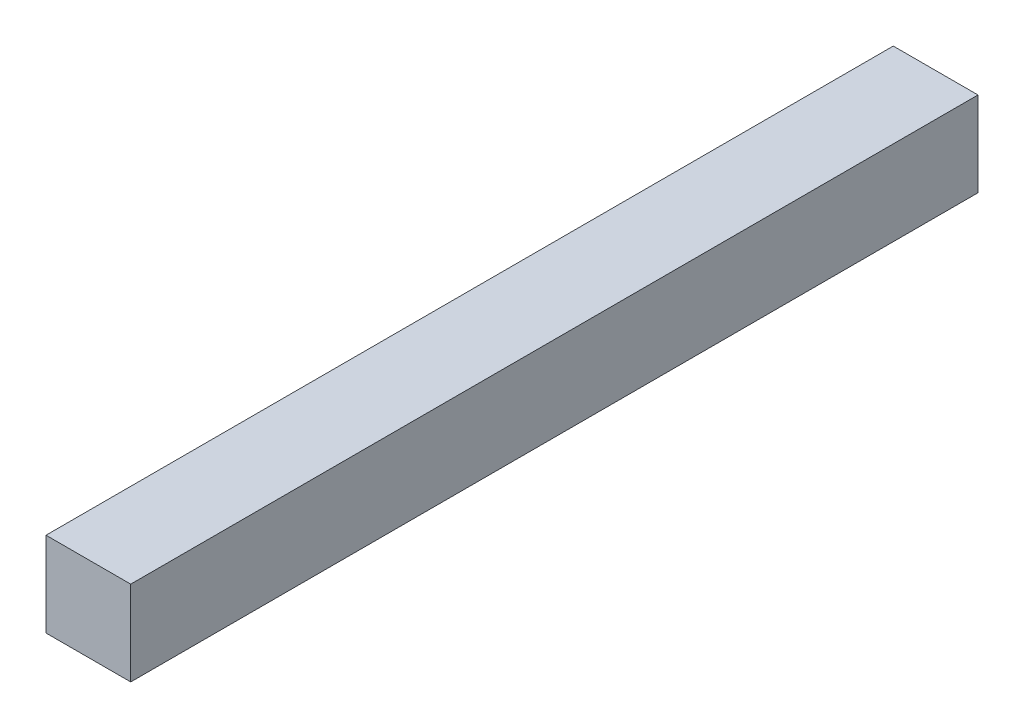
from build123d import *

# Parameters (mm, degrees)
SKETCH1_W           = 5
SKETCH1_H           = 5
BOSS_EXTRUDE1_DEPTH = 50


with BuildPart() as part:
    # Sketch1 → Boss-Extrude1 (new body)
    with BuildSketch(Plane.XY):
        with Locations((2.5, 2.5)):
            Rectangle(SKETCH1_W, SKETCH1_H)
    extrude(amount=BOSS_EXTRUDE1_DEPTH)


solid = part.part
